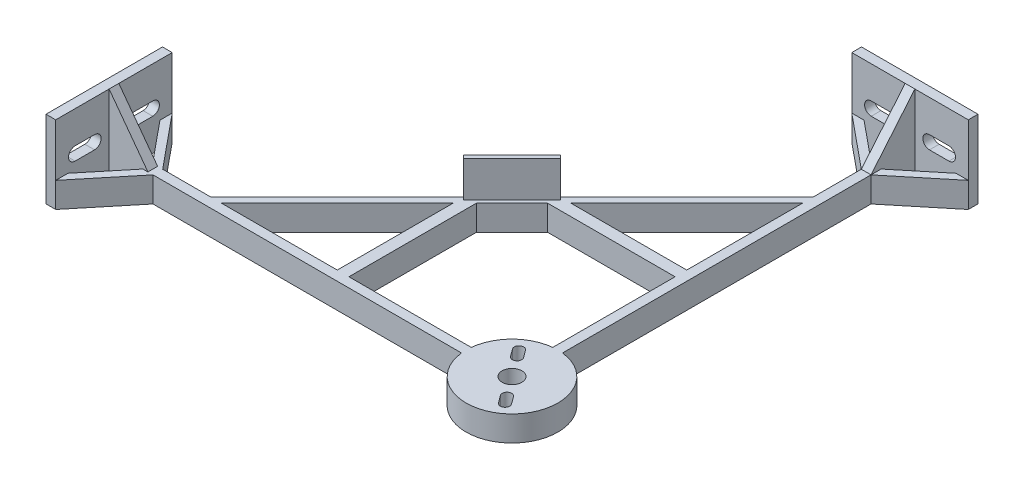
from build123d import *

# Parameters (mm, degrees)
SKETCH1_R                       = 15
BOSS_EXTRUDE2_DEPTH             = 8.255
BOSS_EXTRUDE3_DEPTH             = 8.255
SKETCH5_R                       = 3.249999977
CUT_EXTRUDE3_DEPTH              = 63.5
SKETCH7_W                       = 3.175
SKETCH7_H                       = 25.4
BOSS_EXTRUDE5_DEPTH             = 19.05
CUT_EXTRUDE6_DEPTH              = 149.35
CIRPATTERN2_COUNT               = 2
CIRPATTERN2_ANGLE               = 90
CIRPATTERN3_COUNT               = 2
CIRPATTERN3_ANGLE               = 90
BOSS_EXTRUDE6_DEPTH             = 8.255
BOSS_EXTRUDE7_REACH             = 21.05
BOSS_EXTRUDE7_DIRECTION_2_REACH = 135.35
BOSS_EXTRUDE8_REACH             = 21.05
BOSS_EXTRUDE8_DIRECTION_2_REACH = 135.35
BOSS_EXTRUDE9_REACH             = 133.763
SKETCH19_W                      = 3.81
SKETCH19_H                      = 8.255
BOSS_EXTRUDE10_REACH            = 133.763
SKETCH20_W                      = 3.81
SKETCH20_H                      = 8.255
SKETCH21_W                      = 22.352
SKETCH21_H                      = 20.066
BOSS_EXTRUDE11_DEPTH            = 1.27


with BuildPart() as part:
    # Sketch1 → Boss-Extrude2 (new body)
    with BuildSketch(Plane(origin=(0, 0, 0), x_dir=(1, 0, 0), z_dir=(0, 1, 0))):
        Circle(SKETCH1_R)
    extrude(amount=BOSS_EXTRUDE2_DEPTH)

    # Sketch1_6 → Boss-Extrude3 (add)
    with BuildSketch(Plane(origin=(0, 0, 0), x_dir=(1, 0, 0), z_dir=(0, 1, 0))):
        with BuildLine():
            Line((-1.5875, 130.175), (-1.5875, 14.915758236))
            ThreePointArc((-1.5875, 14.915758236), (0, 15), (1.5875, 14.915758236))
            Line((1.5875, 14.915758236), (1.5875, 130.175))
            Line((1.5875, 130.175), (-1.5875, 130.175))
        make_face()
        with BuildLine():
            ThreePointArc((-14.915758236, -1.5875), (-15, 0), (-14.915758236, 1.5875))
            Line((-14.915758236, 1.5875), (-130.175, 1.5875))
            Line((-130.175, 1.5875), (-130.175, -1.5875))
            Line((-130.175, -1.5875), (-14.915758236, -1.5875))
        make_face()
    extrude(amount=BOSS_EXTRUDE3_DEPTH)

    # Sketch5 → Cut-Extrude3 (cut)
    with BuildSketch(Plane(origin=(0, 8.255, 0), x_dir=(1, 0, 0), z_dir=(0, 1, 0))):
        Circle(SKETCH5_R)
        with BuildLine():
            Line((-5.908712478, 5.423058993), (-7.721732332, 7.873214705))
            ThreePointArc((-7.721732332, 7.873214705), (-7.403164404, 10.004802487), (-5.271576621, 9.686234559))
            Line((-5.271576621, 9.686234559), (-3.458556767, 7.236078848))
            ThreePointArc((-3.458556767, 7.236078848), (-3.777124696, 5.104491065), (-5.908712478, 5.423058993))
        make_face()
        with BuildLine():
            Line((3.458556767, -7.236078848), (5.271576621, -9.686234559))
            ThreePointArc((5.271576621, -9.686234559), (7.403164404, -10.004802487), (7.721732332, -7.873214705))
            Line((7.721732332, -7.873214705), (5.908712478, -5.423058993))
            ThreePointArc((5.908712478, -5.423058993), (3.777124696, -5.104491065), (3.458556767, -7.236078848))
        make_face()
    extrude(amount=-CUT_EXTRUDE3_DEPTH, mode=Mode.SUBTRACT)

    # Sketch7 → Boss-Extrude5 (add, symmetric)
    with BuildSketch(Plane(origin=(0, 0, 0), x_dir=(0, 0, -1), z_dir=(1, 0, 0))):
        with Locations((131.7625, 12.7)):
            Rectangle(SKETCH7_W, SKETCH7_H)
    boss_extrude5 = extrude(amount=BOSS_EXTRUDE5_DEPTH, both=True)

    # Sketch12 → Cut-Extrude6 (cut, through all)
    with BuildSketch(Plane(origin=(0, 0, -133.35), x_dir=(-1, 0, 0), z_dir=(0, 0, -1))):
        with BuildLine():
            Line((-6.35, 10.541), (-12.7, 10.541))
            ThreePointArc((-12.7, 10.541), (-14.859, 12.7), (-12.7, 14.859))
            Line((-12.7, 14.859), (-6.35, 14.859))
            ThreePointArc((-6.35, 14.859), (-4.191, 12.7), (-6.35, 10.541))
        make_face()
        with BuildLine():
            Line((6.35, 14.859), (12.7, 14.859))
            ThreePointArc((12.7, 14.859), (14.859, 12.7), (12.7, 10.541))
            Line((12.7, 10.541), (6.35, 10.541))
            ThreePointArc((6.35, 10.541), (4.191, 12.7), (6.35, 14.859))
        make_face()
    cut_extrude6 = extrude(amount=-CUT_EXTRUDE6_DEPTH, mode=Mode.SUBTRACT)

    # CirPattern2: Boss-Extrude5 ×2 about axis
    cirpattern2_axis = Axis((0, 0, 0), (0, 1, 0))
    for i in range(1, CIRPATTERN2_COUNT):
        add(boss_extrude5.rotate(cirpattern2_axis, i * CIRPATTERN2_ANGLE / (CIRPATTERN2_COUNT - 1)))

    # CirPattern3: Cut-Extrude6 ×2 about axis
    cirpattern3_axis = Axis((0, 0, 0), (0, 1, 0))
    for i in range(1, CIRPATTERN3_COUNT):
        add(cut_extrude6.rotate(cirpattern3_axis, i * CIRPATTERN3_ANGLE / (CIRPATTERN3_COUNT - 1)), mode=Mode.SUBTRACT)

    # Sketch13 → Boss-Extrude6 (add)
    with BuildSketch(Plane.XZ):
        Polygon((-96.628948776, -1.5875), (-1.5875, -96.628948776), (-1.5875, -100.221051224), (-100.221051224, -1.5875), align=None)
        Polygon((-19.05, -130.175), (-1.5875, -115.831500599), (-1.5875, -119.118499401), (-15.048241783, -130.175), align=None)
        Polygon((19.05, -130.175), (1.5875, -115.831500599), (1.5875, -119.118499401), (15.048241783, -130.175), align=None)
        Polygon((-119.118499401, 1.5875), (-130.175, 15.048241783), (-130.175, 19.05), (-115.831500599, 1.5875), align=None)
        Polygon((-119.118499401, -1.5875), (-130.175, -15.048241783), (-130.175, -19.05), (-115.831500599, -1.5875), align=None)
    extrude(amount=-BOSS_EXTRUDE6_DEPTH)

    # Boss-Extrude7: up to this face of the body (flat: up to its plane)
    boss_extrude7_end = Plane(part.part.faces().sort_by_distance((-124.646749701, 4.1275, 1.5875))[0])
    # Sketch14 → Boss-Extrude7 (add, up to the picked face)
    with BuildSketch(Plane.XY, mode=Mode.PRIVATE) as boss_extrude7_sk1:
        Polygon((-130.175, 25.4), (-117.475, 8.255), (-130.175, 8.255), align=None)
    boss_extrude7_tool1 = split(extrude(boss_extrude7_sk1.sketch, amount=BOSS_EXTRUDE7_REACH, mode=Mode.PRIVATE), bisect_by=boss_extrude7_end, keep=Keep.BOTH, mode=Mode.PRIVATE)
    add(boss_extrude7_tool1.solids().sort_by_distance((-125.941667, 13.97, 0))[0])

    # Boss-Extrude7 direction 2: up to this face of the body (flat: up to its plane)
    boss_extrude7_direction_2_end = Plane(part.part.faces().sort_by_distance((-124.646749701, 4.1275, -1.5875))[0])
    # Sketch14 → Boss-Extrude7 direction 2 (add, up to the picked face)
    with BuildSketch(Plane.XY, mode=Mode.PRIVATE) as boss_extrude7_direction_2_sk1:
        Polygon((-130.175, 25.4), (-117.475, 8.255), (-130.175, 8.255), align=None)
    boss_extrude7_direction_2_tool1 = split(extrude(boss_extrude7_direction_2_sk1.sketch, amount=-BOSS_EXTRUDE7_DIRECTION_2_REACH, mode=Mode.PRIVATE), bisect_by=boss_extrude7_direction_2_end, keep=Keep.BOTH, mode=Mode.PRIVATE)
    add(boss_extrude7_direction_2_tool1.solids().sort_by_distance((-125.941667, 13.97, 0))[0])

    # Boss-Extrude8: up to this face of the body (flat: up to its plane)
    boss_extrude8_end = Plane(part.part.faces().sort_by_distance((1.5875, 4.1275, -65.373629417))[0])
    # Sketch15 → Boss-Extrude8 (add, up to the picked face)
    with BuildSketch(Plane(origin=(0, 0, 0), x_dir=(0, 0, -1), z_dir=(1, 0, 0)), mode=Mode.PRIVATE) as boss_extrude8_sk1:
        Polygon((130.175, 25.4), (115.831500599, 8.255), (130.175, 8.255), align=None)
    boss_extrude8_tool1 = split(extrude(boss_extrude8_sk1.sketch, amount=BOSS_EXTRUDE8_REACH, mode=Mode.PRIVATE), bisect_by=boss_extrude8_end, keep=Keep.BOTH, mode=Mode.PRIVATE)
    add(boss_extrude8_tool1.solids().sort_by_distance((0, 13.97, -125.393834))[0])

    # Boss-Extrude8 direction 2: up to this face of the body (flat: up to its plane)
    boss_extrude8_direction_2_end = Plane(part.part.faces().sort_by_distance((-1.5875, 4.1275, -108.026275912))[0])
    # Sketch15 → Boss-Extrude8 direction 2 (add, up to the picked face)
    with BuildSketch(Plane(origin=(0, 0, 0), x_dir=(0, 0, -1), z_dir=(1, 0, 0)), mode=Mode.PRIVATE) as boss_extrude8_direction_2_sk1:
        Polygon((130.175, 25.4), (115.831500599, 8.255), (130.175, 8.255), align=None)
    boss_extrude8_direction_2_tool1 = split(extrude(boss_extrude8_direction_2_sk1.sketch, amount=-BOSS_EXTRUDE8_DIRECTION_2_REACH, mode=Mode.PRIVATE), bisect_by=boss_extrude8_direction_2_end, keep=Keep.BOTH, mode=Mode.PRIVATE)
    add(boss_extrude8_direction_2_tool1.solids().sort_by_distance((0, 13.97, -125.393834))[0])

    # Sketch19 → Boss-Extrude9 (add, up to next)
    with BuildSketch(Plane.ZY.offset(1.5875), mode=Mode.PRIVATE) as boss_extrude9_sk1:
        with Locations((-56.825758236, 4.1275)):
            Rectangle(SKETCH19_W, SKETCH19_H)
    boss_extrude9_tool1 = extrude(boss_extrude9_sk1.sketch, amount=BOSS_EXTRUDE9_REACH, mode=Mode.PRIVATE) - part.part
    add(boss_extrude9_tool1.solids().sort_by_distance((-1.5875, 4.1275, -56.825758))[0])

    # Sketch20 → Boss-Extrude10 (add, up to next)
    with BuildSketch(Plane(origin=(0, 0, -1.5875), x_dir=(-1, 0, 0), z_dir=(0, 0, -1)), mode=Mode.PRIVATE) as boss_extrude10_sk1:
        with Locations((56.825758236, 4.1275)):
            Rectangle(SKETCH20_W, SKETCH20_H)
    boss_extrude10_tool1 = extrude(boss_extrude10_sk1.sketch, amount=BOSS_EXTRUDE10_REACH, mode=Mode.PRIVATE) - part.part
    add(boss_extrude10_tool1.solids().sort_by_distance((-56.825758, 4.1275, -1.5875))[0])

    # Sketch21 → Boss-Extrude11 (add)
    with BuildSketch(Plane(origin=(-50.00625, 0, -50.00625), x_dir=(-0.707106781, 0, 0.707106781), z_dir=(-0.707106781, 0, -0.707106781))):
        with Locations((0, 10.033)):
            Rectangle(SKETCH21_W, SKETCH21_H)
    extrude(amount=BOSS_EXTRUDE11_DEPTH)


solid = part.part
